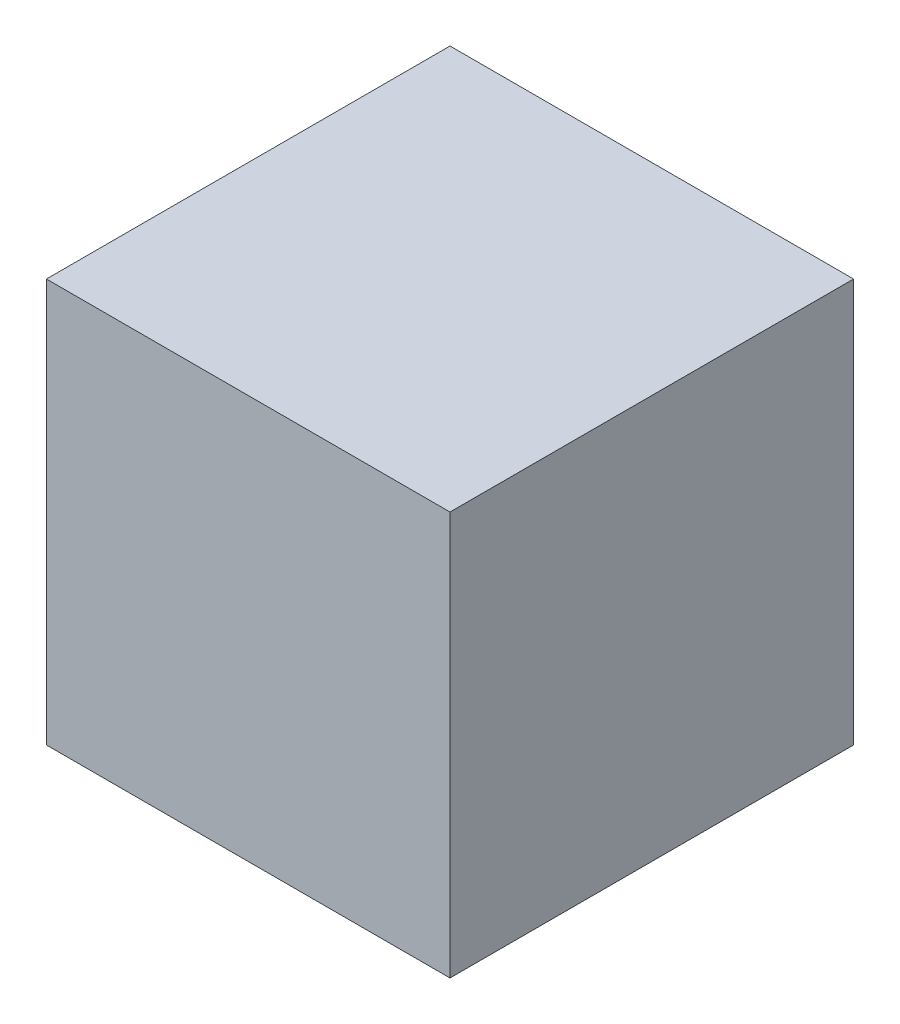
from build123d import *

# Parameters (mm, degrees)
ESBO_O1_W                = 10
ESBO_O1_H                = 10
RESSALTO_EXTRUS_O1_DEPTH = 10


with BuildPart() as part:
    # Esboço1 → Ressalto-extrusão1 (new body)
    with BuildSketch(Plane.XY):
        Rectangle(ESBO_O1_W, ESBO_O1_H)
    extrude(amount=RESSALTO_EXTRUS_O1_DEPTH)


solid = part.part
